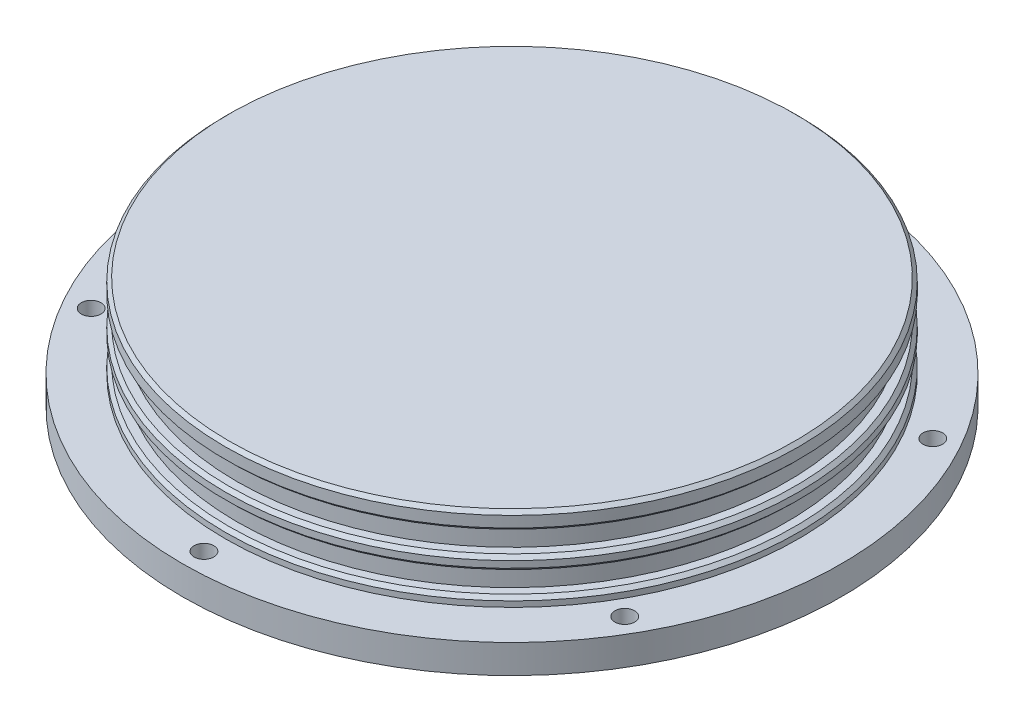
from build123d import *

# Parameters (mm, degrees)
SKETCH1_R                       = 36.5125
EXTRUDE1_DEPTH                  = 3.175
SKETCH2_R                       = 31.75
EXTRUDE2_DEPTH                  = 9.2075
SKETCH4_W                       = 1.27
SKETCH4_H                       = 2.3622
CHAMFER1_SIZE                   = 0.381
F_2_56_TAPPED_HOLE1_D           = 1.778
F_2_56_TAPPED_HOLE1_DEPTH       = 5.588
F_2_56_TAPPED_HOLE1_CBORE_D     = 2.1844
F_2_56_TAPPED_HOLE1_CBORE_DEPTH = 4.318
F_2_56_TAPPED_HOLE1_TIP         = 0.53416509


with BuildPart() as part:
    # Sketch1 → Extrude1 (new body)
    with BuildSketch(Plane(origin=(0, 0, 0), x_dir=(1, 0, 0), z_dir=(0, 1, 0))):
        Circle(SKETCH1_R)
    extrude(amount=EXTRUDE1_DEPTH)

    # Sketch2 → Extrude2 (add)
    with BuildSketch(Plane(origin=(0, 3.175, 0), x_dir=(-1, 0, 0), z_dir=(0, 1, 0))):
        Circle(SKETCH2_R)
    extrude(amount=EXTRUDE2_DEPTH)

    # Sketch4 → Cut-Revolve7 (revolve, cut)
    with BuildSketch(Plane(origin=(0, 0, 0), x_dir=(0, 0, -1), z_dir=(1, 0, 0))):
        with Locations((-31.115, 9.224034757)):
            Rectangle(SKETCH4_W, SKETCH4_H)
        with Locations((-31.115, 5.360539726)):
            Rectangle(SKETCH4_W, SKETCH4_H)
    revolve(axis=Axis((0, 0, 0), (0, 1, 0)), mode=Mode.SUBTRACT)

    # Chamfer1
    chamfer1_edges = [part.edges().sort_by_distance(p)[0] for p in [
        (31.75, 10.405134757, 0),
        (31.75, 8.042934757, 0),
        (31.75, 6.541639726, 0),
        (31.75, 4.179439726, 0),
        (31.75, 12.3825, 0),
    ]]
    chamfer(chamfer1_edges, length=CHAMFER1_SIZE)

    # #2-56 Tapped Hole1
    with Locations(Plane(origin=(-29.558529563, 0, 17.065625), x_dir=(0, 0, -1), z_dir=(0, -1, 0))):
        with Locations((0, 0), (-17.065625, 29.558529563), (0, 59.117059126), (34.13125, 59.117059126), (51.196875, 29.558529563), (34.13125, 0)):
            CounterBoreHole(F_2_56_TAPPED_HOLE1_D / 2, F_2_56_TAPPED_HOLE1_CBORE_D / 2, F_2_56_TAPPED_HOLE1_CBORE_DEPTH, depth=F_2_56_TAPPED_HOLE1_DEPTH)
            with Locations((0, 0, -(F_2_56_TAPPED_HOLE1_DEPTH + F_2_56_TAPPED_HOLE1_TIP / 2))):  # 118° drill point
                Cone(0, F_2_56_TAPPED_HOLE1_D / 2, F_2_56_TAPPED_HOLE1_TIP, mode=Mode.SUBTRACT)


solid = part.part
